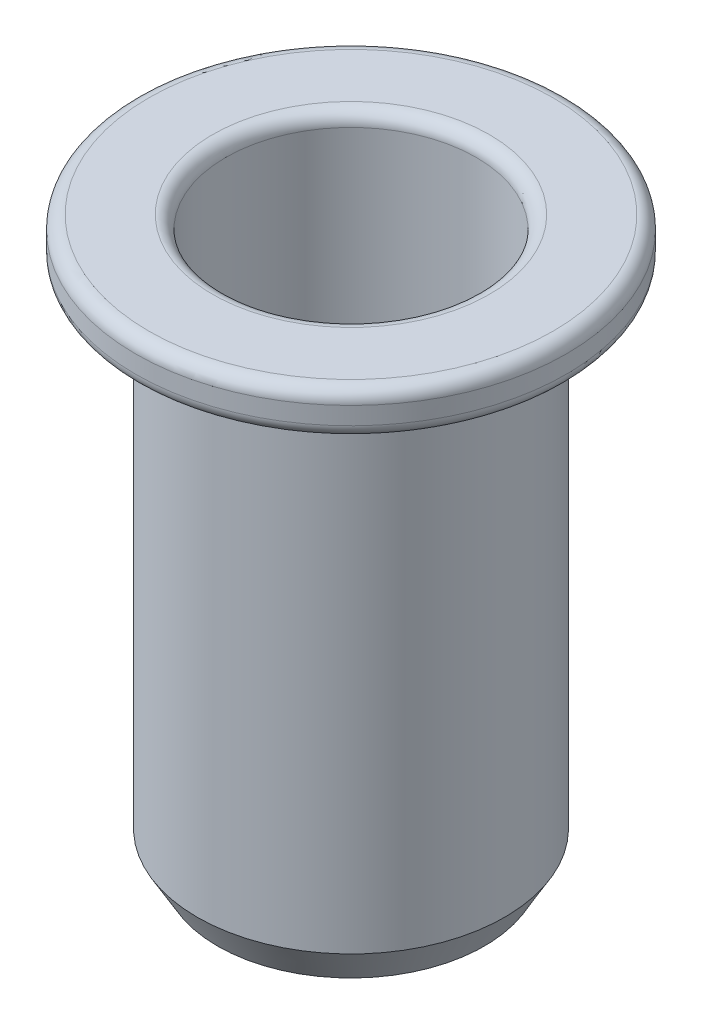
from build123d import *

# Parameters (mm, degrees)
FILLET1_R      = 0.3
CHAMFER1_SIZE  = 0.8
CHAMFER1_SIZE2 = 0.461880215
CHAMFER2_SIZE  = 0.5
CHAMFER2_SIZE2 = 0.288675135


with BuildPart() as part:
    # Sketch1 → Revolve1 (revolve)
    with BuildSketch(Plane.XY):
        Polygon((2.85, 0), (4.9, 0), (4.9, -1), (3.5, -1), (3.5, -12.9), (2.5, -12.9), (2.5, -5.7), (2.85, -5.7), align=None)
    revolve(axis=Axis((0, 0, 0), (0, -1, 0)))

    # Fillet1
    fillet1_edges = [part.edges().sort_by_distance(p)[0] for p in [
        (-4.9, -1, 0),
        (-4.9, 0, 0),
        (-2.85, 0, 0),
    ]]
    fillet(fillet1_edges, radius=FILLET1_R)

    # Chamfer1
    chamfer1_edges = [part.edges().sort_by_distance(p)[0] for p in [
        (-3.5, -12.9, 0),
    ]]
    chamfer1_side = [part.faces().sort_by_distance(p)[0] for p in [
        (-3.5, -6.95, 0),
    ]]
    chamfer(chamfer1_edges, length=CHAMFER1_SIZE, length2=CHAMFER1_SIZE2, reference=chamfer1_side[0])

    # Chamfer2
    chamfer2_edges = [part.edges().sort_by_distance(p)[0] for p in [
        (-2.5, -12.9, 0),
    ]]
    chamfer2_side = [part.faces().sort_by_distance(p)[0] for p in [
        (-2.5, -9.3, 0),
    ]]
    chamfer(chamfer2_edges, length=CHAMFER2_SIZE, length2=CHAMFER2_SIZE2, reference=chamfer2_side[0])


solid = part.part
